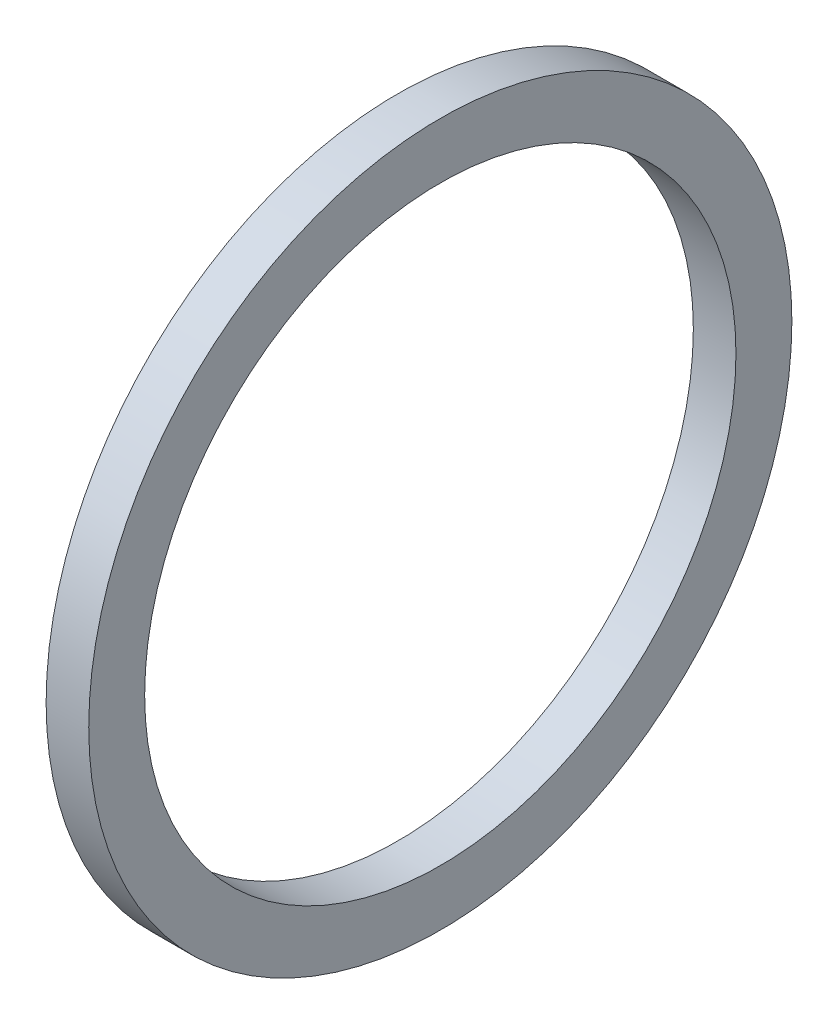
from build123d import *

# Parameters (mm, degrees)
SKETCH1_W = 2.032
SKETCH1_H = 2.667


with BuildPart() as part:
    # Sketch1 → Revolve1 (revolve)
    with BuildSketch(Plane.XY, mode=Mode.PRIVATE) as revolve1_sk:
        with Locations((1.016, -15.4305)):
            Rectangle(SKETCH1_W, SKETCH1_H)
    revolve(revolve1_sk.sketch.rotate(Axis((-43.716580756, 0, 0), (1, 0, 0)), 270), axis=Axis((-43.716580756, 0, 0), (1, 0, 0)))  # turned: the seam where the file's is


solid = part.part
